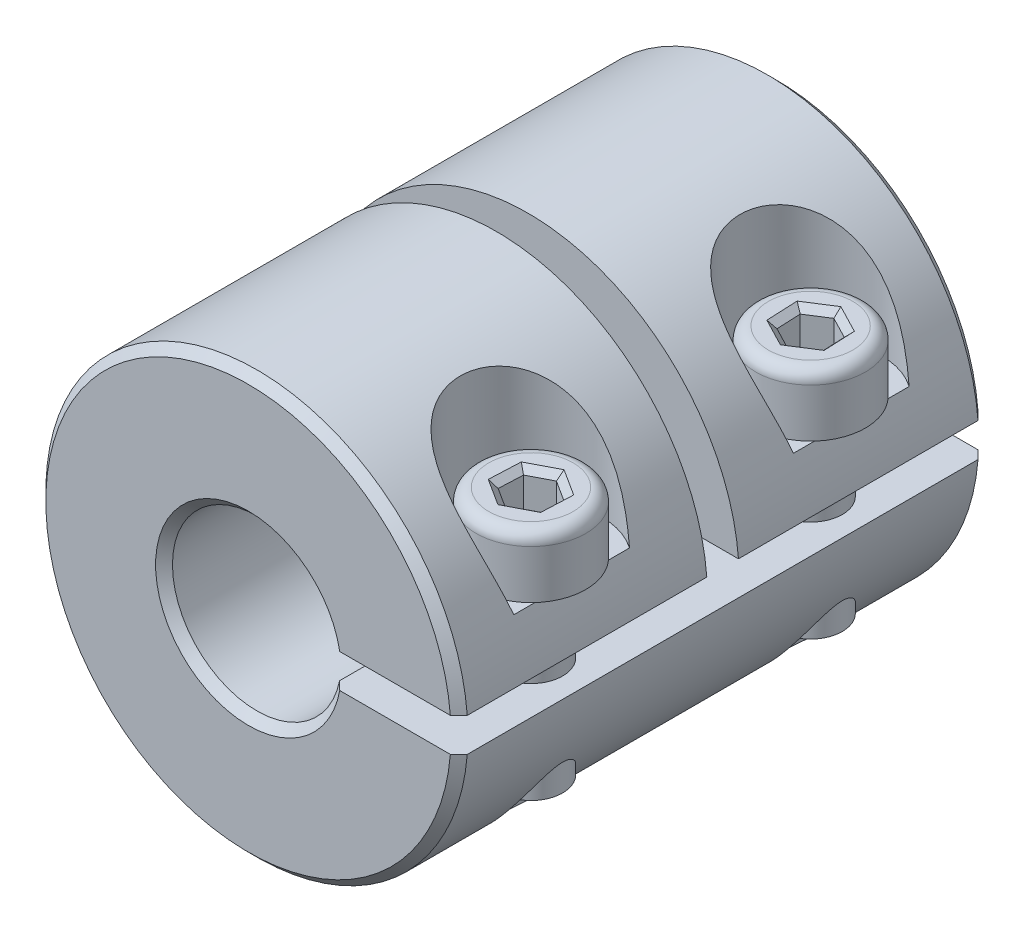
from build123d import *

# Parameters (mm, degrees)
EXTRUDE_1_DEPTH          = 25
EXTRUDE_2_DEPTH          = 7
CUT_EXTRUDE_1_DEPTH      = 29.722813233
CUT_EXTRUDE_1_DEPTH_BACK = 29.722813233
SKETCH_2_W               = 1.5
SKETCH_2_H               = 14.459173422
CUT_EXTRUDE_2_DEPTH      = 29.722813233
CUT_EXTRUDE_2_DEPTH_BACK = 29.722813233
SKETCH_3_R               = 1.5
CUT_EXTRUDE_START        = 3.3
SKETCH_3_3_R             = 3.35
SKETCH_3_3_R_2           = 1.5
CUT_EXTRUDE_3_DEPTH      = 26.422813389
CHAMFER_1_SIZE           = 0.4
SKETCH_4_R               = 2.6
EXTRUDE_3_DEPTH          = 2.9
SKETCH_4_3_R             = 1.5
EXTRUDE_4_DEPTH          = 8.9
CUT_EXTRUDE_4_DEPTH      = 2
FILLET_1_R               = 0.6
CHAMFER_2_SIZE           = 0.3


with BuildPart() as part:
    # Эскиз1 → Бобышка-Вытянуть1 (new body)
    with BuildSketch(Plane.XY):
        with BuildLine():
            Line((9.967948636, -0.8), (3.919183588, -0.8))
            ThreePointArc((3.919183588, -0.8), (-4, 0), (3.919183588, 0.8))
            Line((3.919183588, 0.8), (9.967948636, 0.8))
            ThreePointArc((9.967948636, 0.8), (-10, 0), (9.967948636, -0.8))
        make_face()
    extrude(amount=EXTRUDE_1_DEPTH)

    # Эскиз1<3> → Бобышка-Вытянуть2 (add)
    with BuildSketch(Plane.XY):
        with BuildLine():
            Line((3.919183588, -0.8), (2.368543856, -0.8))
            ThreePointArc((2.368543856, -0.8), (-2.5, 0), (2.368543856, 0.8))
            Line((2.368543856, 0.8), (3.919183588, 0.8))
            ThreePointArc((3.919183588, 0.8), (-4, 0), (3.919183588, -0.8))
        make_face()
    extrude(amount=EXTRUDE_2_DEPTH)

    # Эскиз2 → Вырез-Вытянуть1 (cut, two sides: drawn at the far end of the back side and taken through both)
    with BuildSketch(Plane(origin=(0, 0, 0), x_dir=(0, 0, -1), z_dir=(1, 0, 0)).offset(-CUT_EXTRUDE_1_DEPTH_BACK)):
        with Locations((-12.5, 6.429586711)):
            Rectangle(SKETCH_2_W, SKETCH_2_H)
    extrude(amount=CUT_EXTRUDE_1_DEPTH + CUT_EXTRUDE_1_DEPTH_BACK, mode=Mode.SUBTRACT)

    # Эскиз3 → Вырез-Вытянуть2 (cut, two sides: drawn at the far end of the back side and taken through both)
    with BuildSketch(Plane(origin=(0, 0, 0), x_dir=(1, 0, 0), z_dir=(0, 1, 0)).offset(-CUT_EXTRUDE_2_DEPTH_BACK)):
        with Locations((7.512178364, -5.875)):
            Circle(SKETCH_3_R)
        with Locations((7.512178364, -19.125)):
            Circle(SKETCH_3_R)
    extrude(amount=CUT_EXTRUDE_2_DEPTH + CUT_EXTRUDE_2_DEPTH_BACK, mode=Mode.SUBTRACT)

    # Эскиз3<3> → Вырез-Вытянуть3 (cut, through all)
    # profile 1 of 2: a face of its own
    with BuildSketch(Plane(origin=(0, 0, 0), x_dir=(1, 0, 0), z_dir=(0, 1, 0)).offset(CUT_EXTRUDE_START)):
        with Locations((7.512178364, -5.875)):
            Circle(SKETCH_3_3_R)
        with Locations((7.512178364, -5.875)):
            Circle(SKETCH_3_3_R_2, mode=Mode.SUBTRACT)
    # profile 2 of 2: a face of its own
    with BuildSketch(Plane(origin=(0, 0, 0), x_dir=(1, 0, 0), z_dir=(0, 1, 0)).offset(CUT_EXTRUDE_START)):
        with Locations((7.512178364, -19.125)):
            Circle(SKETCH_3_3_R)
        with Locations((7.512178364, -19.125)):
            Circle(SKETCH_3_3_R_2, mode=Mode.SUBTRACT)
    extrude(amount=CUT_EXTRUDE_3_DEPTH, mode=Mode.SUBTRACT)

    # Фаска1
    chamfer_1_edges = [part.edges().sort_by_distance(p)[0] for p in [
        (-2.5, 0, 0),
        (-10, 0, 0),
        (-4, 0, 25),
        (-10, 0, 25),
    ]]
    chamfer(chamfer_1_edges, length=CHAMFER_1_SIZE)


with BuildPart() as body_2:
    # Эскиз4 → Бобышка-Вытянуть3 (new body)
    with BuildSketch(Plane(origin=(0, 3.3, 0), x_dir=(1, 0, 0), z_dir=(0, 1, 0))):
        with Locations((7.512178364, -5.875)):
            Circle(SKETCH_4_R)
    extrude(amount=EXTRUDE_3_DEPTH)

    # Эскиз4<3> → Бобышка-Вытянуть4 (add)
    with BuildSketch(Plane(origin=(0, 3.3, 0), x_dir=(1, 0, 0), z_dir=(0, 1, 0))):
        with Locations((7.512178364, -5.875)):
            Circle(SKETCH_4_3_R)
    extrude(amount=-EXTRUDE_4_DEPTH)

    # Эскиз5 → Вырез-Вытянуть4 (cut)
    with BuildSketch(Plane(origin=(0, 6.2, 0), x_dir=(1, 0, 0), z_dir=(0, 1, 0))):
        Polygon((8.485442672, -5.253638656), (7.460695809, -4.721447713), (6.487431501, -5.342809057), (6.538914056, -6.496361344), (7.563660919, -7.028552287), (8.536925227, -6.407190943), align=None)
    extrude(amount=-CUT_EXTRUDE_4_DEPTH, mode=Mode.SUBTRACT)

    # Скругление1
    fillet_1_edges = [body_2.edges().sort_by_distance(p)[0] for p in [
        (4.912178364, 6.2, 5.875),
    ]]
    fillet(fillet_1_edges, radius=FILLET_1_R)

    # Фаска2
    chamfer_2_edges = [body_2.edges().sort_by_distance(p)[0] for p in [
        (7.973069241, 6.2, 4.987543184),
        (6.974063655, 6.2, 5.032128385),
        (6.513172779, 6.2, 5.9195852),
        (7.051287488, 6.2, 6.762456816),
        (8.050293073, 6.2, 6.717871615),
        (8.51118395, 6.2, 5.8304148),
        (8.050293073, 4.2, 6.717871615),
        (7.051287488, 4.2, 6.762456816),
        (6.513172779, 4.2, 5.9195852),
        (6.974063655, 4.2, 5.032128385),
        (7.973069241, 4.2, 4.987543184),
        (8.51118395, 4.2, 5.8304148),
    ]]
    chamfer(chamfer_2_edges, length=CHAMFER_2_SIZE)


with BuildPart() as body_3:
    # Зеркальное отражение1: mirrored copy
    add(body_2.part.mirror(Plane.XY.offset(12.5)))


solid = Compound([part.part, body_2.part, body_3.part])
